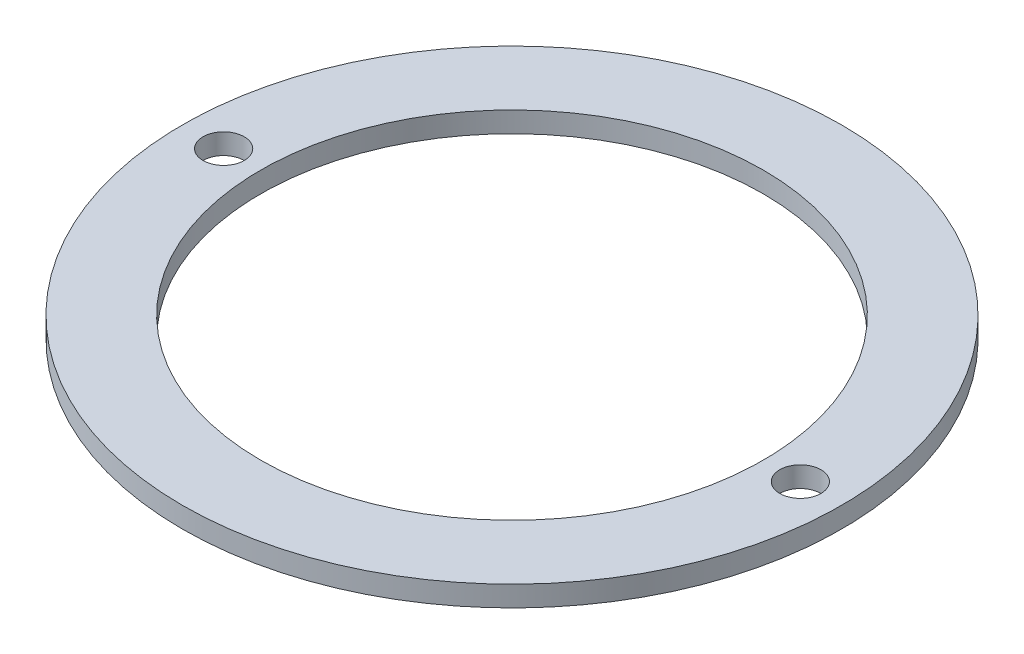
from build123d import *

# Parameters (mm, degrees)
SKETCH1_R                    = 8
BOSS_EXTRUDE1_DEPTH          = 0.5
SKETCH2_R                    = 6.1
CUT_EXTRUDE1_DEPTH           = 1.5
F_1_0_1_DIAMETER_HOLE1_D     = 1
F_1_0_1_DIAMETER_HOLE1_DEPTH = 0.5


with BuildPart() as part:
    # Sketch1 → Boss-Extrude1 (new body)
    with BuildSketch(Plane(origin=(0, 0, 0), x_dir=(1, 0, 0), z_dir=(0, 1, 0))):
        Circle(SKETCH1_R)
    extrude(amount=BOSS_EXTRUDE1_DEPTH)

    # Sketch2 → Cut-Extrude1 (cut, through all)
    with BuildSketch(Plane(origin=(0, 0.5, 0), x_dir=(1, 0, 0), z_dir=(0, 1, 0))):
        Circle(SKETCH2_R)
    extrude(amount=-CUT_EXTRUDE1_DEPTH, mode=Mode.SUBTRACT)

    # Ø1.0 (1) Diameter Hole1
    with Locations(Plane(origin=(0, 0.5, 0), x_dir=(1, 0, 0), z_dir=(0, 1, 0))):
        with Locations((-7, 0), (7, 0)):
            Hole(F_1_0_1_DIAMETER_HOLE1_D / 2, depth=F_1_0_1_DIAMETER_HOLE1_DEPTH)


solid = part.part
